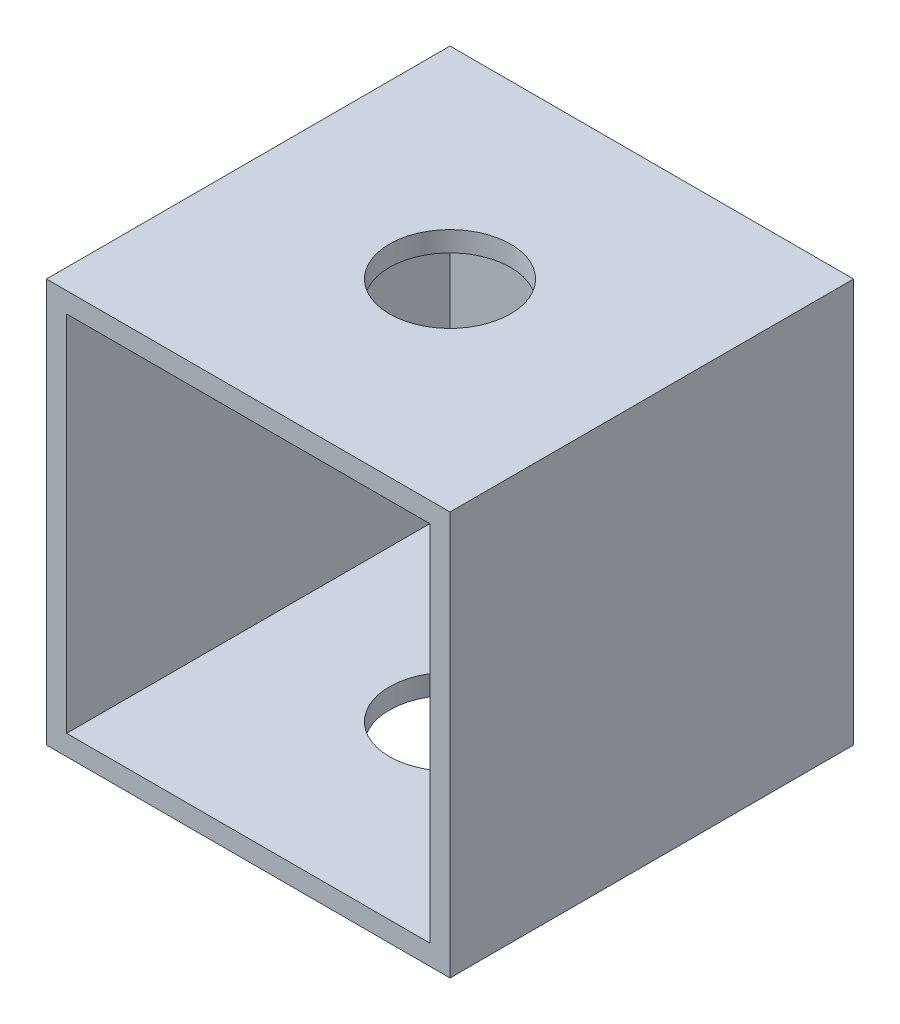
from build123d import *

# Parameters (mm, degrees)
SKETCH1_W           = 40
SKETCH1_H           = 40
BOSS_EXTRUDE1_DEPTH = 40
SHELL1_T            = -2
SKETCH2_R           = 6
CUT_EXTRUDE1_DEPTH  = 40


with BuildPart() as part:
    # Sketch1 → Boss-Extrude1 (new body)
    with BuildSketch(Plane(origin=(0, 0, 0), x_dir=(0, 1, 0), z_dir=(0, 0, 1))):
        Rectangle(SKETCH1_W, SKETCH1_H)
    extrude(amount=BOSS_EXTRUDE1_DEPTH)

    # Shell1
    shell1_openings = [part.faces().sort_by_distance(p)[0] for p in [
        (0, 0, 40),
    ]]
    offset(amount=SHELL1_T, openings=shell1_openings, kind=Kind.INTERSECTION)

    # Sketch2 → Cut-Extrude1 (cut)
    with BuildSketch(Plane(origin=(0, 20, 0), x_dir=(-1, 0, 0), z_dir=(0, 1, 0))):
        with Locations((0, 20)):
            Circle(SKETCH2_R)
    extrude(amount=-CUT_EXTRUDE1_DEPTH, mode=Mode.SUBTRACT)


solid = part.part
